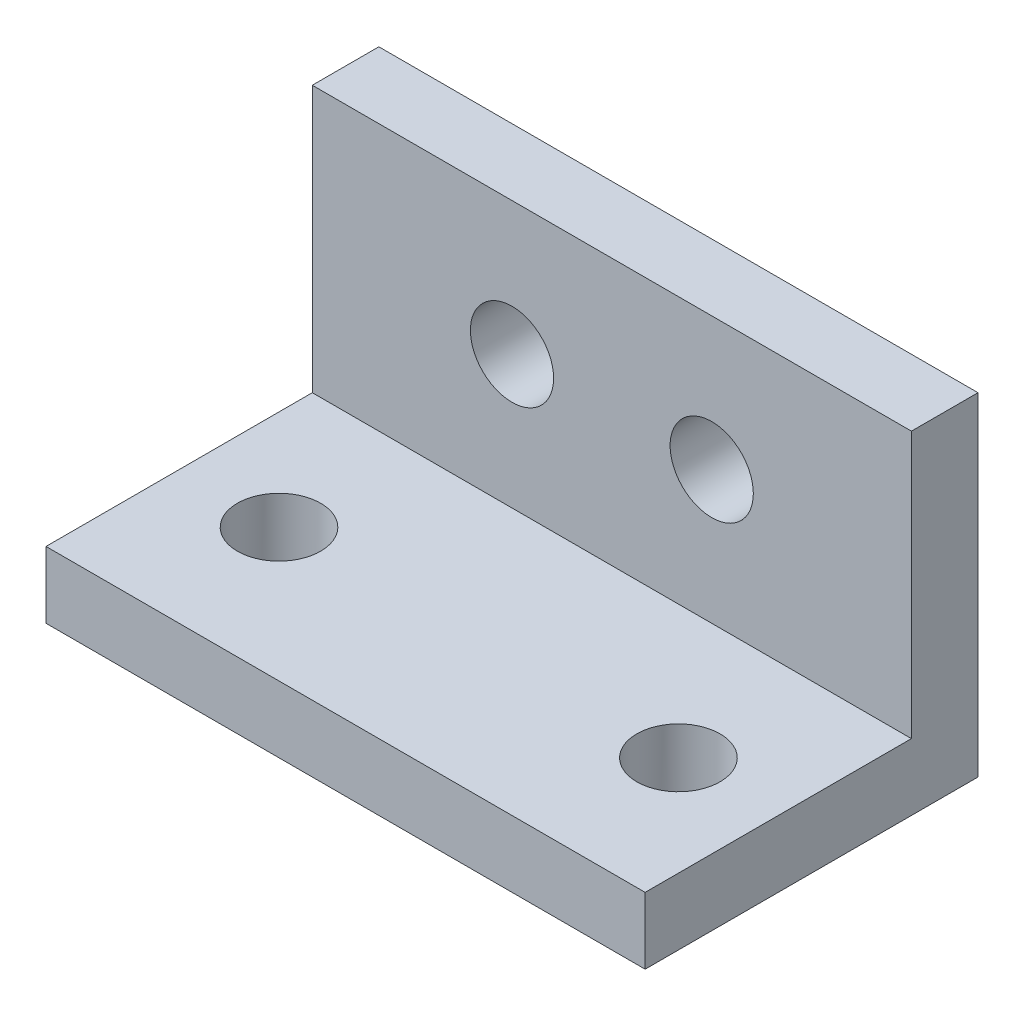
from build123d import *

# Parameters (mm, degrees)
SKETCH1_W           = 25.4
SKETCH1_H           = 6.35
SKETCH1_W_2         = 6.35
SKETCH1_H_2         = 31.75
BOSS_EXTRUDE1_DEPTH = 57.15
CUT_EXTRUDE1_REACH  = 8.35
SKETCH2_R           = 3.96875
CUT_EXTRUDE2_REACH  = 8.35
SKETCH3_R           = 3.96875


with BuildPart() as part:
    # Sketch1 → Boss-Extrude1 (new body)
    with BuildSketch(Plane(origin=(0, 0, 0), x_dir=(0, 0, -1), z_dir=(1, 0, 0))):
        with Locations((-19.05, 3.175)):
            Rectangle(SKETCH1_W, SKETCH1_H)
        with Locations((-3.175, 15.875)):
            Rectangle(SKETCH1_W_2, SKETCH1_H_2)
    extrude(amount=BOSS_EXTRUDE1_DEPTH)

    # Sketch2 → Cut-Extrude1 (cut, up to next)
    with BuildSketch(Plane.XY.offset(6.35), mode=Mode.PRIVATE) as cut_extrude1_sk1:
        with Locations((19.05, 19.05)):
            Circle(SKETCH2_R)
    cut_extrude1_tool1 = extrude(cut_extrude1_sk1.sketch, amount=-CUT_EXTRUDE1_REACH, mode=Mode.PRIVATE) & part.part
    add(cut_extrude1_tool1.solids().sort_by_distance((19.05, 19.05, 6.35))[0], mode=Mode.SUBTRACT)
    # Sketch2 → Cut-Extrude1 (cut, up to next)
    with BuildSketch(Plane.XY.offset(6.35), mode=Mode.PRIVATE) as cut_extrude1_sk2:
        with Locations((38.1, 19.05)):
            Circle(SKETCH2_R)
    cut_extrude1_tool2 = extrude(cut_extrude1_sk2.sketch, amount=-CUT_EXTRUDE1_REACH, mode=Mode.PRIVATE) & part.part
    add(cut_extrude1_tool2.solids().sort_by_distance((38.1, 19.05, 6.35))[0], mode=Mode.SUBTRACT)

    # Sketch3 → Cut-Extrude2 (cut, up to next)
    with BuildSketch(Plane(origin=(0, 6.35, 0), x_dir=(1, 0, 0), z_dir=(0, 1, 0)), mode=Mode.PRIVATE) as cut_extrude2_sk1:
        with Locations((9.525, -19.05)):
            Circle(SKETCH3_R)
    cut_extrude2_tool1 = extrude(cut_extrude2_sk1.sketch, amount=-CUT_EXTRUDE2_REACH, mode=Mode.PRIVATE) & part.part
    add(cut_extrude2_tool1.solids().sort_by_distance((9.525, 6.35, 19.05))[0], mode=Mode.SUBTRACT)
    # Sketch3 → Cut-Extrude2 (cut, up to next)
    with BuildSketch(Plane(origin=(0, 6.35, 0), x_dir=(1, 0, 0), z_dir=(0, 1, 0)), mode=Mode.PRIVATE) as cut_extrude2_sk2:
        with Locations((47.625, -19.05)):
            Circle(SKETCH3_R)
    cut_extrude2_tool2 = extrude(cut_extrude2_sk2.sketch, amount=-CUT_EXTRUDE2_REACH, mode=Mode.PRIVATE) & part.part
    add(cut_extrude2_tool2.solids().sort_by_distance((47.625, 6.35, 19.05))[0], mode=Mode.SUBTRACT)


solid = part.part
